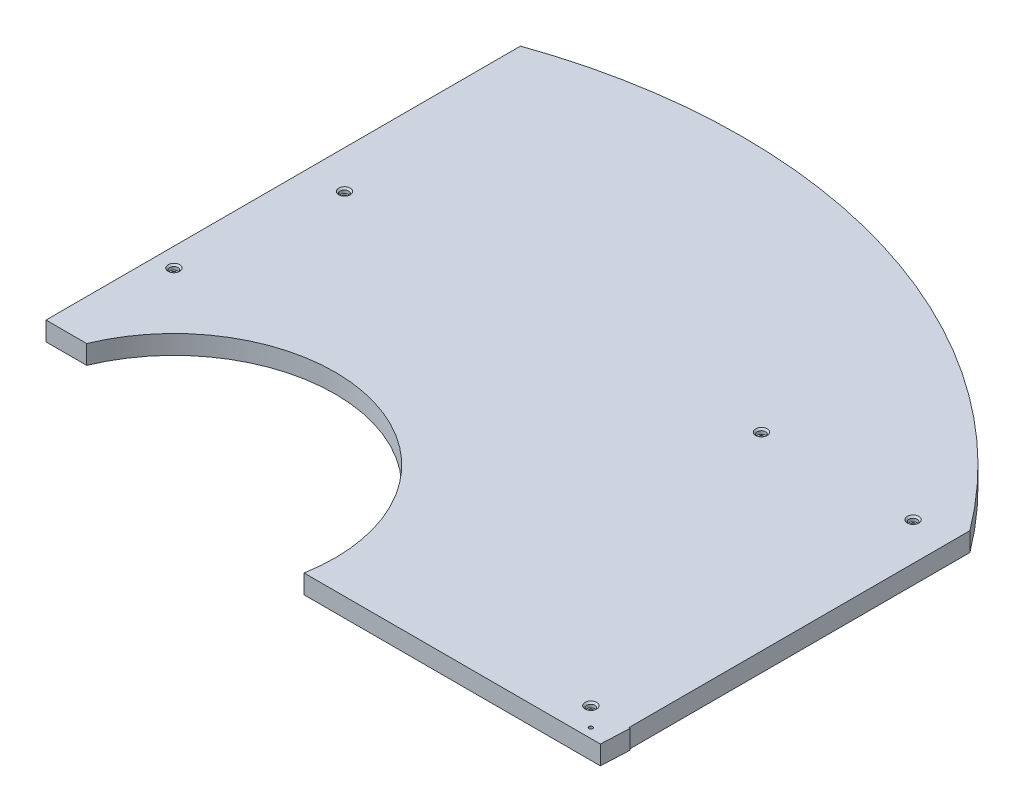
from build123d import *

# Parameters (mm, degrees)
SKETCH2_W                                     = 2006.6
SKETCH2_H                                     = 762
BOSS_EXTRUDE1_DEPTH                           = 25.4
BOSS_EXTRUDE4_DEPTH                           = 25.4
F_1_4_20_TAPPED_HOLE1_D                       = 5.1054
SKETCH5_R                                     = 215.9
CUT_EXTRUDE2_DEPTH                            = 26.4
SKETCH10_W                                    = 304.8
SKETCH10_H                                    = 762
CUT_EXTRUDE5_DEPTH                            = 26.4
SKETCH31_W                                    = 381
SKETCH31_H                                    = 82.55
CUT_EXTRUDE8_DEPTH                            = 26.4
CUT_EXTRUDE9_DEPTH                            = 26.4
CUT_EXTRUDE10_DEPTH                           = 26.4
SKETCH41_W                                    = 838.2
SKETCH41_H                                    = 457.2
CUT_EXTRUDE11_DEPTH                           = 26.4
CBORE_FOR_1_4_SOCKET_HEAD_CAP_SCREW1_AT_COUNT = 2
CBORE_FOR_1_4_SOCKET_HEAD_CAP_SCREW1_AT_PITCH = 204.781346807
CBORE_FOR_1_4_SOCKET_HEAD_CAP_SCREW1_2_COUNT  = 2
CBORE_FOR_1_4_SOCKET_HEAD_CAP_SCREW1_2_PITCH  = 618.530419624
CBORE_FOR_1_4_SOCKET_HEAD_CAP_SCREW1_3_COUNT  = 2
CBORE_FOR_1_4_SOCKET_HEAD_CAP_SCREW1_3_PITCH  = 819.912629492
CBORE_FOR_1_4_SOCKET_HEAD_CAP_SCREW1_4_COUNT  = 2
CBORE_FOR_1_4_SOCKET_HEAD_CAP_SCREW1_4_PITCH  = 813.196778154


with BuildPart() as part:
    # Sketch2 → Boss-Extrude1 (new body)
    with BuildSketch(Plane(origin=(0, 0, 0), x_dir=(1, 0, 0), z_dir=(0, 1, 0))):
        with Locations((596.720248579, 143.454782609)):
            Rectangle(SKETCH2_W, SKETCH2_H)
    extrude(amount=BOSS_EXTRUDE1_DEPTH)

    # Sketch63 → Boss-Extrude4 (add)
    with BuildSketch(Plane(origin=(0, 25.4, 0), x_dir=(1, 0, 0), z_dir=(0, 1, 0))):
        with BuildLine():
            Line((368.120248579, -237.545217391), (763.550813985, -237.545217391))
            Line((763.550813985, -237.545217391), (761.820248579, -275.645217391))
            Line((761.820248579, -275.645217391), (364.731895319, -275.645217391))
            ThreePointArc((364.731895319, -275.645217391), (367.271491927, -256.670403258), (368.120248579, -237.545217391))
        make_face()
    extrude(amount=-BOSS_EXTRUDE4_DEPTH)

    # 1/4-20 Tapped Hole1 (through all)
    with Locations(Plane(origin=(0, 25.4, 0), x_dir=(1, 0, 0), z_dir=(0, 1, 0))):
        with Locations((736.420248579, -262.945217391)):
            Hole(F_1_4_20_TAPPED_HOLE1_D / 2)

    # Sketch5 → Cut-Extrude2 (cut, through all)
    with BuildSketch(Plane(origin=(0, 25.4, 0), x_dir=(1, 0, 0), z_dir=(0, 1, 0))):
        with Locations((152.220248579, -237.545217391)):
            Circle(SKETCH5_R)
    extrude(amount=-CUT_EXTRUDE2_DEPTH, mode=Mode.SUBTRACT)

    # Sketch10 → Cut-Extrude5 (cut, through all)
    with BuildSketch(Plane(origin=(0, 25.4, 0), x_dir=(1, 0, 0), z_dir=(0, 1, 0))):
        with Locations((-254.179751421, 143.454782609)):
            Rectangle(SKETCH10_W, SKETCH10_H)
    extrude(amount=-CUT_EXTRUDE5_DEPTH, mode=Mode.SUBTRACT)

    # Sketch31 → Cut-Extrude8 (cut, through all)
    with BuildSketch(Plane(origin=(0, 25.4, 0), x_dir=(1, 0, 0), z_dir=(0, 1, 0))):
        with Locations((-216.079751421, -196.270217391)):
            Rectangle(SKETCH31_W, SKETCH31_H)
    extrude(amount=-CUT_EXTRUDE8_DEPTH, mode=Mode.SUBTRACT)

    # Sketch39 → Cut-Extrude9 (cut, through all)
    with BuildSketch(Plane(origin=(0, 25.4, 0), x_dir=(1, 0, 0), z_dir=(0, 1, 0))):
        with BuildLine():
            Line((-101.779751421, 480.875272294), (-101.779751421, 524.454782609))
            Line((-101.779751421, 524.454782609), (152.220248579, 524.454782609))
            ThreePointArc((152.220248579, 524.454782609), (23.36454079, 513.480885065), (-101.779751421, 480.875272294))
        make_face()
    extrude(amount=-CUT_EXTRUDE9_DEPTH, mode=Mode.SUBTRACT)

    # Sketch40 → Cut-Extrude10 (cut, through all)
    with BuildSketch(Plane(origin=(0, 25.4, 0), x_dir=(1, 0, 0), z_dir=(0, 1, 0))):
        with BuildLine():
            Line((152.220248579, 524.454782609), (1600.020248579, 524.454782609))
            Line((1600.020248579, 524.454782609), (1600.020248579, 219.654782609))
            Line((1600.020248579, 219.654782609), (761.820248579, 219.654782609))
            ThreePointArc((761.820248579, 219.654782609), (492.99700835, 444.008302151), (152.220248579, 524.454782609))
        make_face()
    extrude(amount=-CUT_EXTRUDE10_DEPTH, mode=Mode.SUBTRACT)

    # Sketch41 → Cut-Extrude11 (cut, through all)
    with BuildSketch(Plane(origin=(0, 25.4, 0), x_dir=(1, 0, 0), z_dir=(0, 1, 0))):
        with Locations((1180.920248579, -8.945217391)):
            Rectangle(SKETCH41_W, SKETCH41_H)
    extrude(amount=-CUT_EXTRUDE11_DEPTH, mode=Mode.SUBTRACT)

    # Sketch67 → CBORE for 1/4 Socket Head Cap Screw1 (revolve, cut)
    with BuildSketch(Plane(origin=(-76.379751421, 25.4, 8.945217391), x_dir=(0, 0, 1), z_dir=(1, 0, 0))):
        Polygon((0, 0), (0, 25.40005), (3.3782, 25.40005), (3.3782, 6.35), (5.55625, 6.35), (5.55625, 2.2225), (7.77875, 0), align=None)
    cbore_for_1_4_socket_head_cap_screw1 = revolve(axis=Axis((-76.379751421, 31.75, 8.945217391), (0, -1, 0)), mode=Mode.SUBTRACT)

    # CBORE for 1/4 Socket Head Cap Screw1 at: CBORE for 1/4 Socket Head Cap Screw1 ×2
    with Locations(*[Vector(0.124034735, 0, -0.992277877) * (i * CBORE_FOR_1_4_SOCKET_HEAD_CAP_SCREW1_AT_PITCH) for i in range(1, CBORE_FOR_1_4_SOCKET_HEAD_CAP_SCREW1_AT_COUNT)]):
        add(cbore_for_1_4_socket_head_cap_screw1, mode=Mode.SUBTRACT)

    # CBORE for 1_4 Socket Head Cap Screw1 2: CBORE for 1/4 Socket Head Cap Screw1 ×2
    with Locations(*[Vector(0.944496797, 0, -0.328520625) * (i * CBORE_FOR_1_4_SOCKET_HEAD_CAP_SCREW1_2_PITCH) for i in range(1, CBORE_FOR_1_4_SOCKET_HEAD_CAP_SCREW1_2_COUNT)]):
        add(cbore_for_1_4_socket_head_cap_screw1, mode=Mode.SUBTRACT)

    # CBORE for 1_4 Socket Head Cap Screw1 3: CBORE for 1/4 Socket Head Cap Screw1 ×2
    with Locations(*[Vector(0.960346227, 0, 0.278810195) * (i * CBORE_FOR_1_4_SOCKET_HEAD_CAP_SCREW1_3_PITCH) for i in range(1, CBORE_FOR_1_4_SOCKET_HEAD_CAP_SCREW1_3_COUNT)]):
        add(cbore_for_1_4_socket_head_cap_screw1, mode=Mode.SUBTRACT)

    # CBORE for 1_4 Socket Head Cap Screw1 4: CBORE for 1/4 Socket Head Cap Screw1 ×2
    with Locations(*[Vector(0.968277324, 0, -0.249878019) * (i * CBORE_FOR_1_4_SOCKET_HEAD_CAP_SCREW1_4_PITCH) for i in range(1, CBORE_FOR_1_4_SOCKET_HEAD_CAP_SCREW1_4_COUNT)]):
        add(cbore_for_1_4_socket_head_cap_screw1, mode=Mode.SUBTRACT)


solid = part.part
